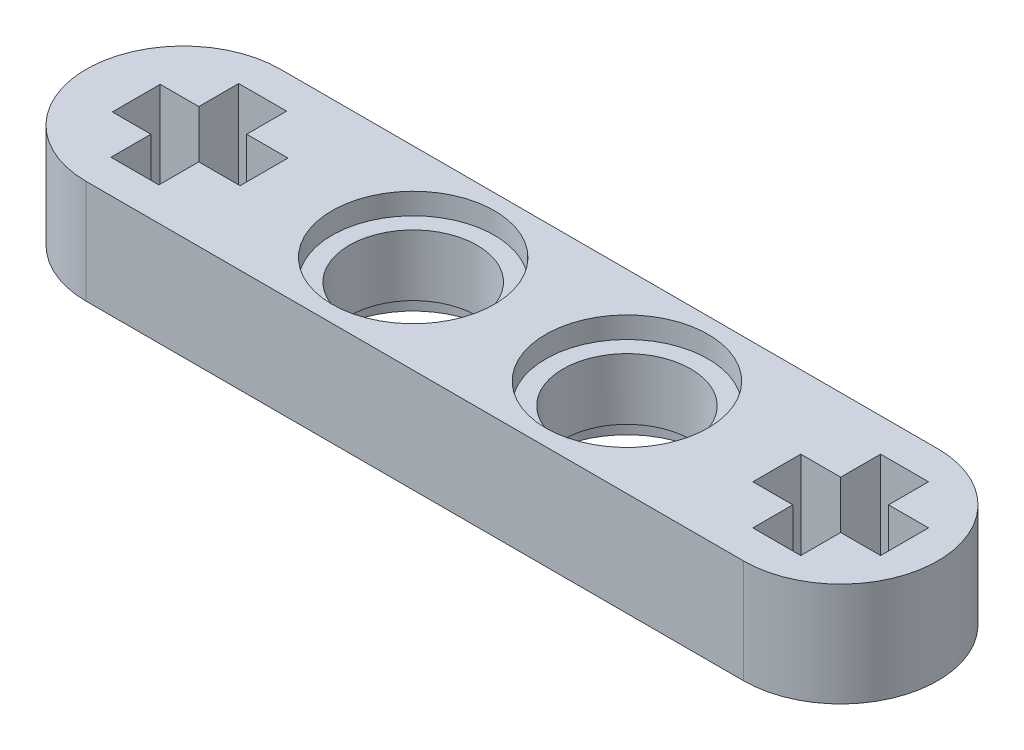
from build123d import *

# Parameters (mm, degrees)
SKETCH1_R           = 2.4
BOSS_EXTRUDE1_DEPTH = 3.9
SKETCH2_R           = 3.05
CUT_EXTRUDE1_DEPTH  = 0.8
SKETCH3_R           = 3.05
CUT_EXTRUDE2_DEPTH  = 0.8


with BuildPart() as part:
    # Sketch1 → Boss-Extrude1 (new body)
    with BuildSketch(Plane(origin=(0, 0, 0), x_dir=(1, 0, 0), z_dir=(0, 1, 0))):
        with BuildLine():
            Line((-12.665, 3.65), (12.035, 3.65))
            ThreePointArc((12.035, 3.65), (15.685, 0), (12.035, -3.65))
            Line((12.035, -3.65), (-12.665, -3.65))
            ThreePointArc((-12.665, -3.65), (-16.315, 0), (-12.665, 3.65))
        make_face()
        with Locations((-4.045, 0.018008222)):
            Circle(SKETCH1_R, mode=Mode.SUBTRACT)
        with Locations((3.995, 0.008270612)):
            Circle(SKETCH1_R, mode=Mode.SUBTRACT)
        Polygon((11.135, 2.4), (11.135, 0.9), (9.635, 0.9), (9.635, -0.9), (11.135, -0.9), (11.135, -2.4), (12.935, -2.4), (12.935, -0.9), (14.435, -0.9), (14.435, 0.9), (12.935, 0.9), (12.935, 2.4), align=None, mode=Mode.SUBTRACT)
        Polygon((-12.985, 2.401087844), (-12.985, 0.901087844), (-14.433060202, 0.901087844), (-14.433060202, -0.898912156), (-12.985, -0.898912156), (-12.985, -2.398912156), (-11.185, -2.398912156), (-11.185, -0.898912156), (-9.633060202, -0.898912156), (-9.633060202, 0.901087844), (-11.185, 0.901087844), (-11.185, 2.401087844), align=None, mode=Mode.SUBTRACT)
    extrude(amount=BOSS_EXTRUDE1_DEPTH)

    # Sketch2 → Cut-Extrude1 (cut)
    with BuildSketch(Plane(origin=(0, 3.9, 0), x_dir=(1, 0, 0), z_dir=(0, 1, 0))):
        with Locations((-4.045, 0.018008222)):
            Circle(SKETCH2_R)
        with Locations((3.995, 0.008270612)):
            Circle(SKETCH2_R)
    extrude(amount=-CUT_EXTRUDE1_DEPTH, mode=Mode.SUBTRACT)

    # Sketch3 → Cut-Extrude2 (cut)
    with BuildSketch(Plane.XZ):
        with Locations((3.995, -0.008270612)):
            Circle(SKETCH3_R)
        with Locations((-4.045, -0.018008222)):
            Circle(SKETCH3_R)
    extrude(amount=-CUT_EXTRUDE2_DEPTH, mode=Mode.SUBTRACT)


solid = part.part
